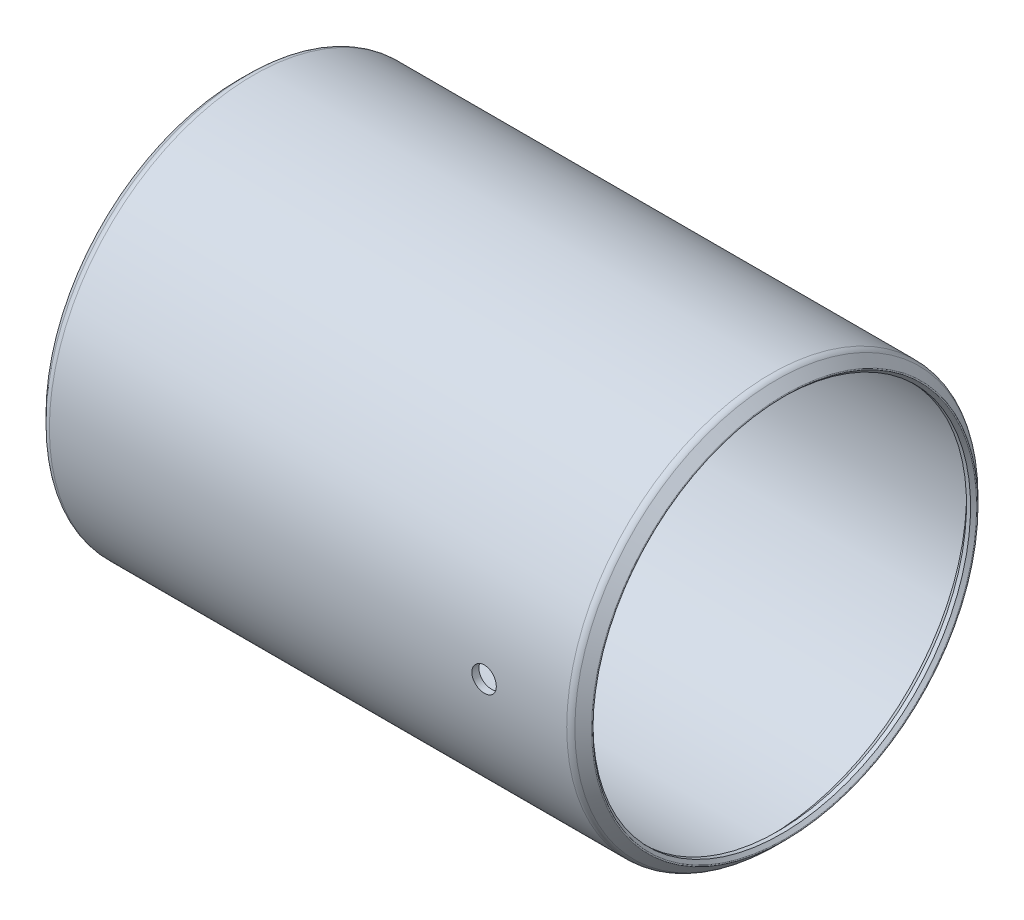
from build123d import *

# Parameters (mm, degrees)
SKETCH2_R          = 1.5875
CUT_EXTRUDE1_DEPTH = 26.48585


with BuildPart() as part:
    # Sketch1 → Revolve1 (revolve)
    with BuildSketch(Plane.XY):
        with BuildLine():
            Line((-0.919083697, 24.909383697), (-0.52705, 24.51735))
            Line((-0.52705, 24.51735), (0, 24.51735))
            Line((0, 24.51735), (1.0541, 25.57145))
            Line((1.0541, 25.57145), (67.9577, 25.57145))
            Line((67.9577, 25.57145), (69.0118, 24.51735))
            Line((69.0118, 24.51735), (69.53885, 24.51735))
            Line((69.53885, 24.51735), (69.930883697, 24.909383697))
            ThreePointArc((69.930883697, 24.909383697), (69.968081136, 24.999186258), (69.930883697, 25.088988819))
            Line((69.930883697, 25.088988819), (68.842761258, 26.177111258))
            ThreePointArc((68.842761258, 26.177111258), (68.500786606, 26.405611415), (68.0974, 26.48585))
            Line((68.0974, 26.48585), (0.9144, 26.48585))
            ThreePointArc((0.9144, 26.48585), (0.511013394, 26.405611415), (0.169038742, 26.177111258))
            Line((0.169038742, 26.177111258), (-0.919083697, 25.088988819))
            ThreePointArc((-0.919083697, 25.088988819), (-0.956281136, 24.999186258), (-0.919083697, 24.909383697))
        make_face()
    revolve(axis=Axis((69.0118, 0, 0), (-1, 0, 0)))

    # Sketch2 → Cut-Extrude1 (cut)
    with BuildSketch(Plane.XY):
        with Locations((57.3659, 0)):
            Circle(SKETCH2_R)
    extrude(amount=CUT_EXTRUDE1_DEPTH, mode=Mode.SUBTRACT)


solid = part.part
